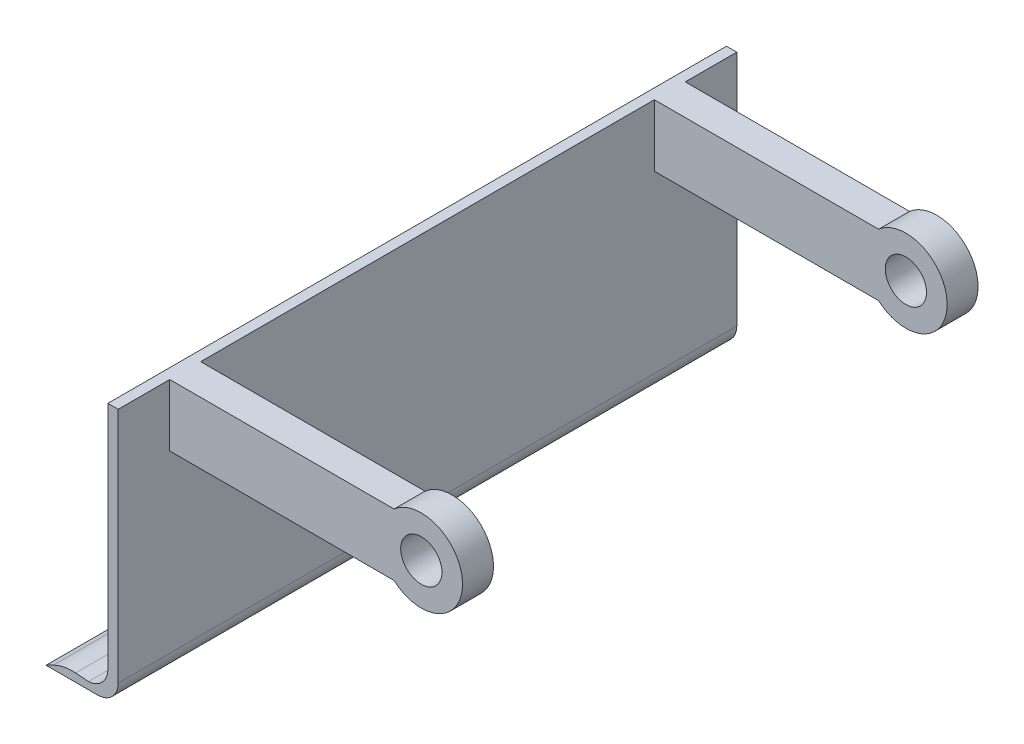
from build123d import *

# Parameters (mm, degrees)
BOSS_EXTRU_1_DEPTH      = 300
ESQUISSE3_W             = 15
ESQUISSE3_H             = 30
BOSS_EXTRU_2_DEPTH      = 115
ESQUISSE4_R             = 20
BOSS_EXTRU_3_DEPTH      = 15
ESQUISSE6_R             = 20
BOSS_EXTRU_4_DEPTH      = 15
ESQUISSE5_R             = 10
ENL_V_MAT_EXTRU_1_DEPTH = 276


with BuildPart() as part:
    # Esquisse1 → Boss.-Extru.1 (new body)
    with BuildSketch(Plane.XY):
        with BuildLine():
            Line((-5, 125), (-5, 35))
            Line((-5, 35), (-5, 13.417991274))
            ThreePointArc((-5, 13.417991274), (-7.715430946, 6.567075008), (-14.387010739, 3.436796748))
            Line((-14.387010739, 3.436796748), (-20.619947118, 3.962528759))
            ThreePointArc((-20.619947118, 3.962528759), (-26.167850826, 3.655908021), (-31.417293187, 1.834752694))
            Line((-31.417293187, 1.834752694), (-35, 0))
            Line((-35, 0), (-10, 0))
            ThreePointArc((-10, 0), (-2.928932188, 2.928932188), (0, 10))
            Line((0, 10), (0, 30))
            Line((0, 30), (0, 125))
            Line((0, 125), (-5, 125))
        make_face()
    extrude(amount=BOSS_EXTRU_1_DEPTH)

    # Esquisse3 → Boss.-Extru.2 (add)
    with BuildSketch(Plane(origin=(0, 0, 0), x_dir=(0, 0, -1), z_dir=(1, 0, 0))):
        with Locations((-267.5, 110)):
            Rectangle(ESQUISSE3_W, ESQUISSE3_H)
        with Locations((-32.5, 110)):
            Rectangle(ESQUISSE3_W, ESQUISSE3_H)
    extrude(amount=BOSS_EXTRU_2_DEPTH)

    # Esquisse4 → Boss.-Extru.3 (add)
    with BuildSketch(Plane.XY.offset(275)):
        with Locations((122, 110)):
            Circle(ESQUISSE4_R)
    extrude(amount=-BOSS_EXTRU_3_DEPTH)

    # Esquisse6 → Boss.-Extru.4 (add)
    with BuildSketch(Plane.XY.offset(40)):
        with Locations((122, 110)):
            Circle(ESQUISSE6_R)
    extrude(amount=-BOSS_EXTRU_4_DEPTH)

    # Esquisse5 → Enlèv. mat.-Extru.1 (cut, through all)
    with BuildSketch(Plane.XY.offset(275)):
        with Locations((122, 110)):
            Circle(ESQUISSE5_R)
    extrude(amount=-ENL_V_MAT_EXTRU_1_DEPTH, mode=Mode.SUBTRACT)


solid = part.part
